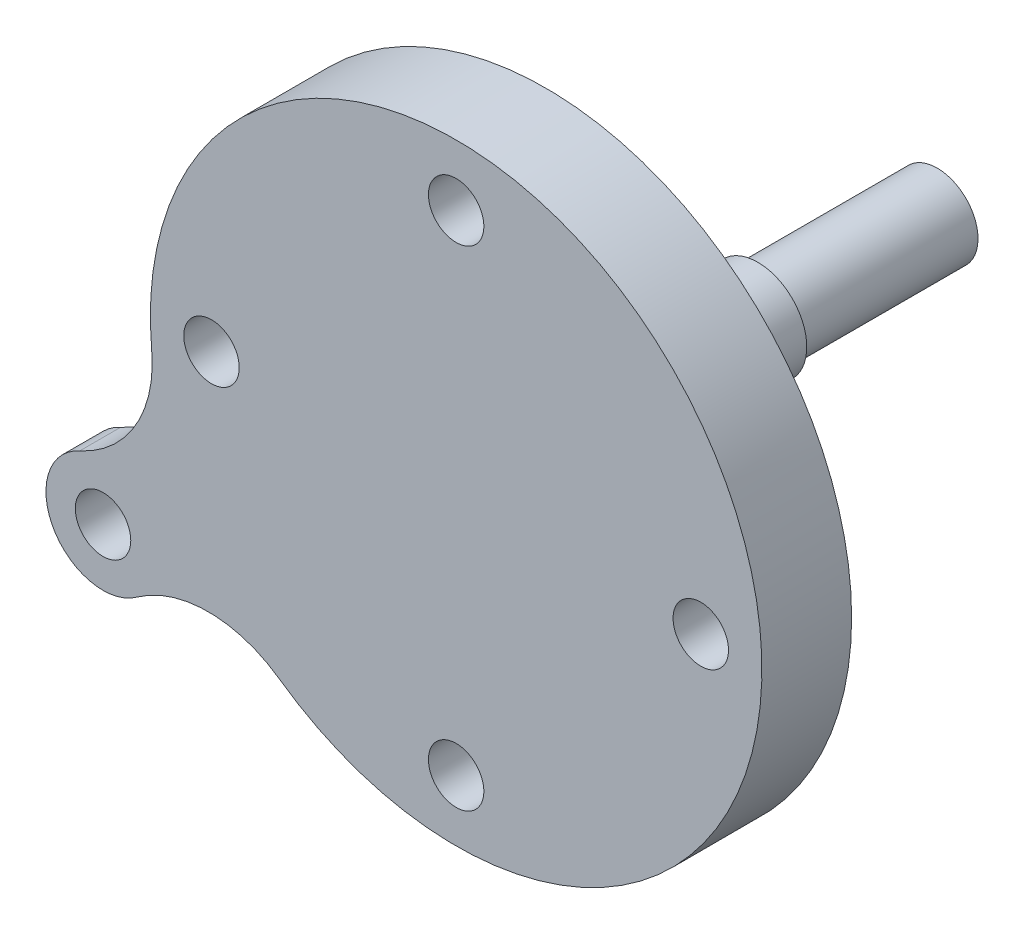
from build123d import *

# Parameters (mm, degrees)
SKETCH1_R                                     = 37.5
BOSS_EXTRUDE1_DEPTH                           = 11
TAP_DRILL_FOR_M8_TAP1_D                       = 6.8
TAP_DRILL_FOR_M8_TAP1_DEPTH                   = 23
TAP_DRILL_FOR_M8_TAP1_TIP                     = 2.042926105
SKETCH6_R                                     = 12
BOSS_EXTRU_1_DEPTH                            = 1
SKETCH5_R                                     = 10
BOSS_EXTRU_2_DEPTH                            = 11
ESQUISSE1_R                                   = 6
BOSS_EXTRU_3_DEPTH                            = 14
ESQUISSE4_R                                   = 5
BOSS_EXTRU_4_DEPTH                            = 22
TROU_POUR_TARAUDAGE_POUR_TROU_TARAUD_M6_D     = 5
TROU_POUR_TARAUDAGE_POUR_TROU_TARAUD_M6_DEPTH = 23
TROU_POUR_TARAUDAGE_POUR_TROU_TARAUD_M6_TIP   = 1.502151548
ENL_V_START                                   = -3.2
ENL_V_MAT_EXTRU_1_DEPTH                       = 10
BOSS_EXTRU_5_DEPTH                            = 5
TROU_POUR_TARAUDAGE_POUR_TROU_TARAUD_M8_D     = 6.8
TROU_POUR_TARAUDAGE_POUR_TROU_TARAUD_M8_DEPTH = 8
TROU_POUR_TARAUDAGE_POUR_TROU_TARAUD_M8_TIP   = 2.042926105


with BuildPart() as part:
    # Sketch1 → Boss-Extrude1 (new body)
    with BuildSketch(Plane.XY):
        Circle(SKETCH1_R)
    extrude(amount=BOSS_EXTRUDE1_DEPTH)

    # Tap Drill for M8 Tap1
    with Locations(Plane.XY.offset(11)):
        with Locations((-30, 0), (0, 30), (30, 0), (0, -30)):
            Hole(TAP_DRILL_FOR_M8_TAP1_D / 2, depth=TAP_DRILL_FOR_M8_TAP1_DEPTH)
            with Locations((0, 0, -(TAP_DRILL_FOR_M8_TAP1_DEPTH + TAP_DRILL_FOR_M8_TAP1_TIP / 2))):  # 118° drill point
                Cone(0, TAP_DRILL_FOR_M8_TAP1_D / 2, TAP_DRILL_FOR_M8_TAP1_TIP, mode=Mode.SUBTRACT)

    # Sketch6 → Boss.-Extru.1 (add)
    with BuildSketch(Plane(origin=(0, 0, 0), x_dir=(-1, 0, 0), z_dir=(0, 0, -1))):
        Circle(SKETCH6_R)
    extrude(amount=BOSS_EXTRU_1_DEPTH)

    # Sketch5 → Boss.-Extru.2 (add)
    with BuildSketch(Plane(origin=(0, 0, -1), x_dir=(-1, 0, 0), z_dir=(0, 0, -1))):
        Circle(SKETCH5_R)
    extrude(amount=BOSS_EXTRU_2_DEPTH)

    # Esquisse1 → Boss.-Extru.3 (add)
    with BuildSketch(Plane(origin=(0, 0, -12), x_dir=(-1, 0, 0), z_dir=(0, 0, -1))):
        Circle(ESQUISSE1_R)
    extrude(amount=BOSS_EXTRU_3_DEPTH)

    # Esquisse4 → Boss.-Extru.4 (add)
    with BuildSketch(Plane(origin=(0, 0, -26), x_dir=(-1, 0, 0), z_dir=(0, 0, -1))):
        Circle(ESQUISSE4_R)
    extrude(amount=BOSS_EXTRU_4_DEPTH)

    # Trou pour taraudage pour trou taraudé M61
    with Locations(Plane(origin=(0, 0, -48), x_dir=(-1, 0, 0), z_dir=(0, 0, -1))):
        with Locations((0, 0)):
            Hole(TROU_POUR_TARAUDAGE_POUR_TROU_TARAUD_M6_D / 2, depth=TROU_POUR_TARAUDAGE_POUR_TROU_TARAUD_M6_DEPTH)
            with Locations((0, 0, -(TROU_POUR_TARAUDAGE_POUR_TROU_TARAUD_M6_DEPTH + TROU_POUR_TARAUDAGE_POUR_TROU_TARAUD_M6_TIP / 2))):  # 118° drill point
                Cone(0, TROU_POUR_TARAUDAGE_POUR_TROU_TARAUD_M6_D / 2, TROU_POUR_TARAUDAGE_POUR_TROU_TARAUD_M6_TIP, mode=Mode.SUBTRACT)

    # Esquisse5 → Enlèv. mat.-Extru.1 (cut)
    with BuildSketch(Plane(origin=(0, 0, 0), x_dir=(1, 0, 0), z_dir=(0, 1, 0)).offset(ENL_V_START)):
        with BuildLine():
            Line((-1.5, 27.923988696), (-1.5, 48))
            ThreePointArc((-1.5, 48), (0, 49.5), (1.5, 48))
            Line((1.5, 48), (1.5, 27.923988696))
            ThreePointArc((1.5, 27.923988696), (0, 26.423988696), (-1.5, 27.923988696))
        make_face()
    extrude(amount=-ENL_V_MAT_EXTRU_1_DEPTH, mode=Mode.SUBTRACT)

    # Esquisse6 → Boss.-Extru.5 (add)
    with BuildSketch(Plane.XY.offset(11)):
        with BuildLine():
            ThreePointArc((-46.154891817, -18.608064174), (-49.363448016, -28.5), (-39.192502198, -30.667276735))
            ThreePointArc((-39.192502198, -30.667276735), (-30.463205965, -27.811629704), (-21.705713829, -30.579600834))
            ThreePointArc((-21.705713829, -30.579600834), (-32.475952642, -18.75), (-37.335568074, -3.507899166))
            ThreePointArc((-37.335568074, -3.507899166), (-39.317180827, -12.476095394), (-46.154891817, -18.608064174))
        make_face()
    extrude(amount=-BOSS_EXTRU_5_DEPTH)

    # Trou pour taraudage pour trou taraudé M81
    with Locations(Plane.XY.offset(11)):
        with Locations((-43.301270189, -25)):
            Hole(TROU_POUR_TARAUDAGE_POUR_TROU_TARAUD_M8_D / 2, depth=TROU_POUR_TARAUDAGE_POUR_TROU_TARAUD_M8_DEPTH)
            with Locations((0, 0, -(TROU_POUR_TARAUDAGE_POUR_TROU_TARAUD_M8_DEPTH + TROU_POUR_TARAUDAGE_POUR_TROU_TARAUD_M8_TIP / 2))):  # 118° drill point
                Cone(0, TROU_POUR_TARAUDAGE_POUR_TROU_TARAUD_M8_D / 2, TROU_POUR_TARAUDAGE_POUR_TROU_TARAUD_M8_TIP, mode=Mode.SUBTRACT)


solid = part.part
